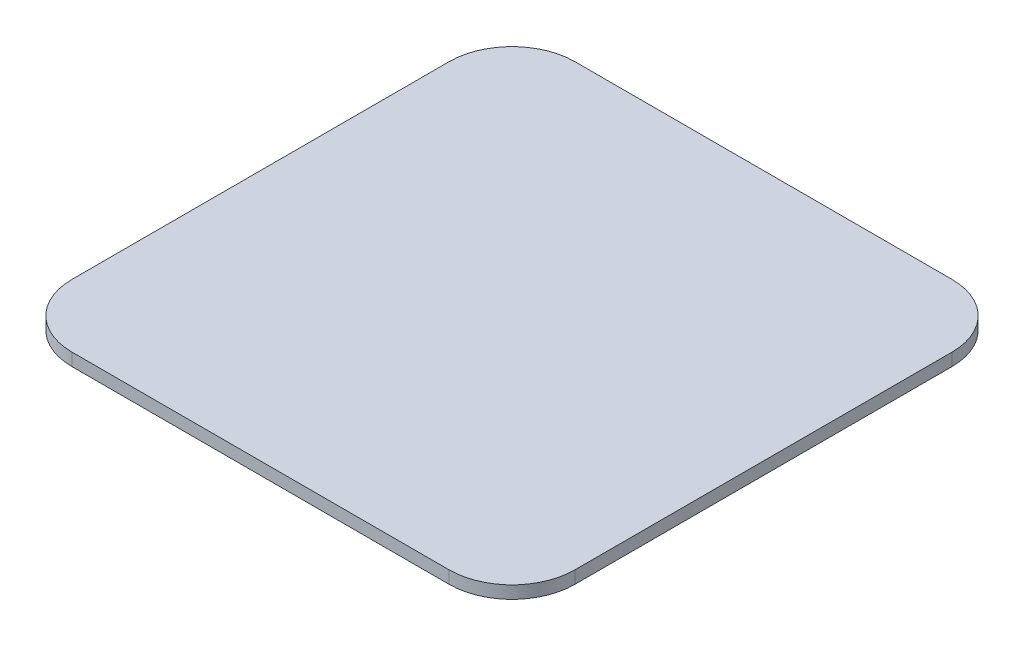
from build123d import *

# Parameters (mm, degrees)
EXTRUDE_1_DEPTH = 1


with BuildPart() as part:
    # 草图1 → 凸台-拉伸1 (new body)
    with BuildSketch(Plane(origin=(0, 0, 0), x_dir=(1, 0, 0), z_dir=(0, 1, 0))):
        with BuildLine():
            Line((-15, 20), (15, 20))
            ThreePointArc((15, 20), (18.535533906, 18.535533906), (20, 15))
            Line((20, 15), (20, -15))
            ThreePointArc((20, -15), (18.535533906, -18.535533906), (15, -20))
            Line((15, -20), (-15, -20))
            ThreePointArc((-15, -20), (-18.535533906, -18.535533906), (-20, -15))
            Line((-20, -15), (-20, 15))
            ThreePointArc((-20, 15), (-18.535533906, 18.535533906), (-15, 20))
        make_face()
    extrude(amount=EXTRUDE_1_DEPTH)


solid = part.part
